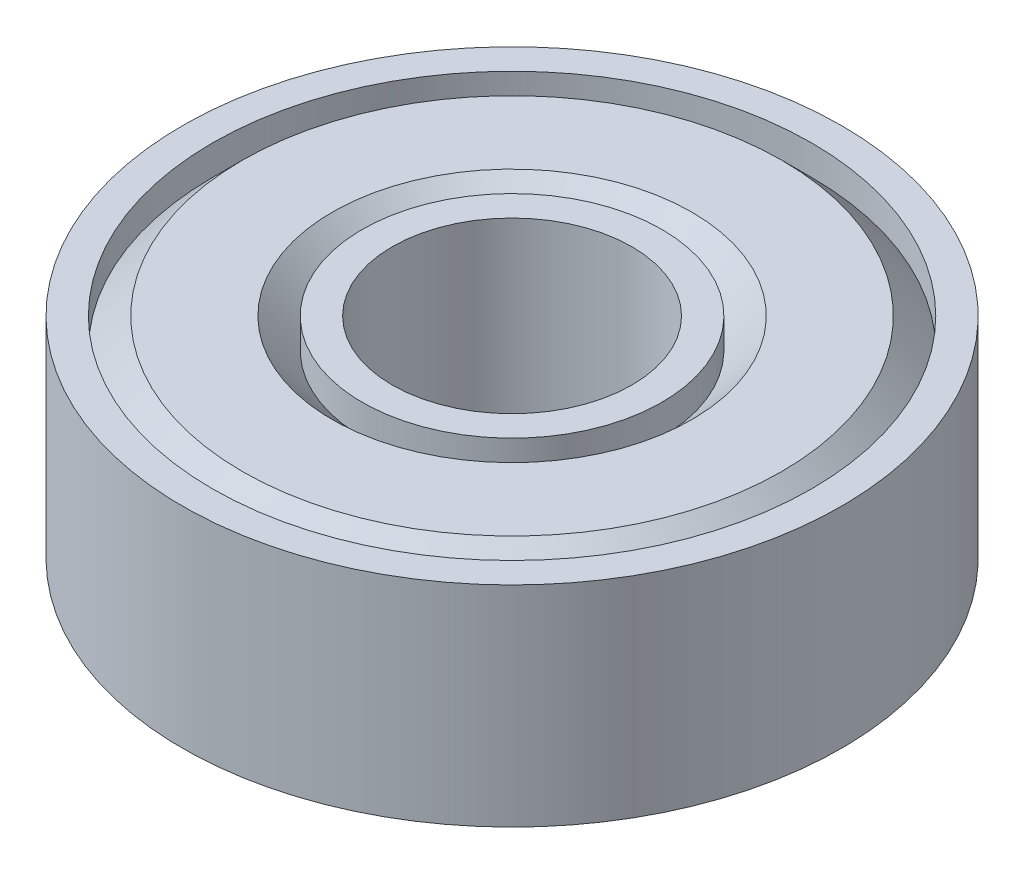
from build123d import *


with BuildPart() as part:
    # 草图1 → 旋转1 (revolve)
    with BuildSketch(Plane.XY):
        Polygon((-20, 0), (-19, 0), (-19, 7), (-20, 7), (-20, 6), (-21, 7), (-24, 7), (-25, 6), (-25, 7), (-26, 7), (-26, 0), (-25, 0), (-25, 1), (-24, 0), (-21, 0), (-20, 1), align=None)
    revolve(axis=Axis((-30, 7, 0), (0, -1, 0)))


solid = part.part
